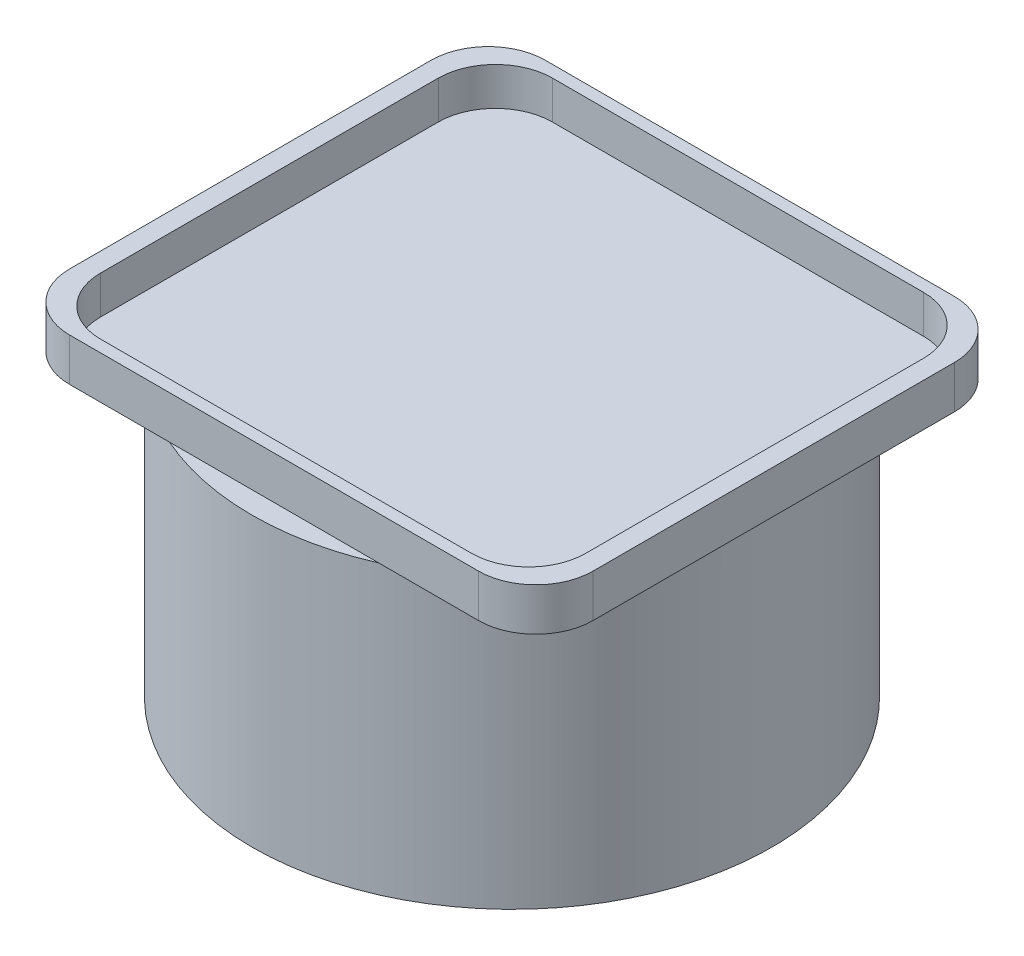
from build123d import *

# Parameters (mm, degrees)
BOSS_EXTRUDE1_DEPTH = 2.032
BOSS_EXTRUDE2_DEPTH = 0.254
SKETCH3_R           = 13.87475
BOSS_EXTRUDE3_DEPTH = 15.35


with BuildPart() as part:
    # Sketch1 → Boss-Extrude1 (new body)
    with BuildSketch(Plane(origin=(0, 0, 0), x_dir=(1, 0, 0), z_dir=(0, 1, 0))):
        with BuildLine():
            Line((-10.922, -12.7), (10.922, -12.7))
            ThreePointArc((10.922, -12.7), (13.077261469, -11.807261469), (13.97, -9.652))
            Line((13.97, -9.652), (13.97, 9.652))
            ThreePointArc((13.97, 9.652), (13.077261469, 11.807261469), (10.922, 12.7))
            Line((10.922, 12.7), (-10.922, 12.7))
            ThreePointArc((-10.922, 12.7), (-13.077261469, 11.807261469), (-13.97, 9.652))
            Line((-13.97, 9.652), (-13.97, -9.652))
            ThreePointArc((-13.97, -9.652), (-13.077261469, -11.807261469), (-10.922, -12.7))
        make_face()
        with BuildLine():
            Line((-9.906, -12.065), (9.906, -12.065))
            ThreePointArc((9.906, -12.065), (12.061261469, -11.172261469), (12.954, -9.017))
            Line((12.954, -9.017), (12.954, 9.017))
            ThreePointArc((12.954, 9.017), (12.061261469, 11.172261469), (9.906, 12.065))
            Line((9.906, 12.065), (-9.906, 12.065))
            ThreePointArc((-9.906, 12.065), (-12.061261469, 11.172261469), (-12.954, 9.017))
            Line((-12.954, 9.017), (-12.954, -9.017))
            ThreePointArc((-12.954, -9.017), (-12.061261469, -11.172261469), (-9.906, -12.065))
        make_face(mode=Mode.SUBTRACT)
    extrude(amount=BOSS_EXTRUDE1_DEPTH)

    # Sketch2 → Boss-Extrude2 (add)
    with BuildSketch(Plane.XZ):
        with BuildLine():
            Line((-10.922, -12.7), (10.922, -12.7))
            ThreePointArc((10.922, -12.7), (13.077261469, -11.807261469), (13.97, -9.652))
            Line((13.97, -9.652), (13.97, 9.652))
            ThreePointArc((13.97, 9.652), (13.077261469, 11.807261469), (10.922, 12.7))
            Line((10.922, 12.7), (-10.922, 12.7))
            ThreePointArc((-10.922, 12.7), (-13.077261469, 11.807261469), (-13.97, 9.652))
            Line((-13.97, 9.652), (-13.97, -9.652))
            ThreePointArc((-13.97, -9.652), (-13.077261469, -11.807261469), (-10.922, -12.7))
        make_face()
    extrude(amount=BOSS_EXTRUDE2_DEPTH)

    # Sketch3 → Boss-Extrude3 (add)
    with BuildSketch(Plane.XZ.offset(0.254)):
        Circle(SKETCH3_R)
    extrude(amount=BOSS_EXTRUDE3_DEPTH)


solid = part.part
